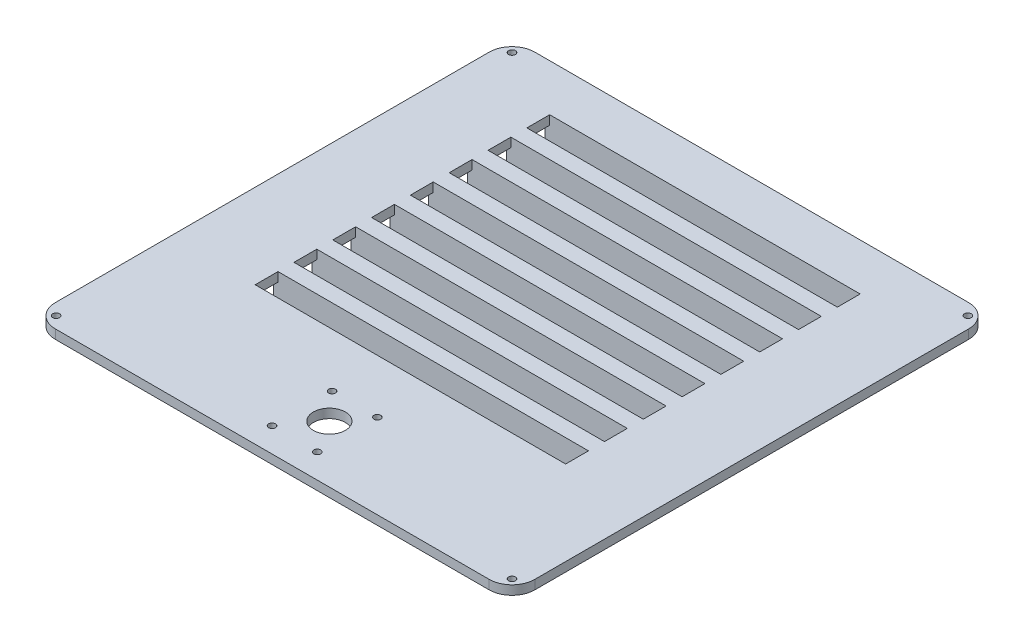
from build123d import *

# Parameters (mm, degrees)
SKETCH1_W               = 210
SKETCH1_H               = 210
MAINEXTRUDE_DEPTH       = 4
SKETCH1_6_R             = 1.5
SCREWHOLES_DEPTH        = 4
ROUNDEDCORNERS_R        = 10
SKETCH3_R               = 7
SKETCH3_R_2             = 1.5
SKETCH3_W               = 136
SKETCH3_H               = 10
TRENCH_DEPTH            = 10
SKETCH4_W               = 140
SKETCH4_H               = 14
SKETCH4_W_2             = 136
SKETCH4_H_2             = 10
TRENCH_WALLS_DEPTH      = 4
SKETCH5_W               = 140
SKETCH5_H               = 14
TRENCH_BOTTOM_DEPTH     = 2
SKETCH7_W               = 10
SKETCH7_H               = 6
WIRE_OPENING_DEPTH      = 36
WIRE_OPENING_DEPTH_BACK = 176
SKETCH9_R               = 2
SKETCH9_R_2             = 0.98
PCB_HOLES_DEPTH         = 4
PCB_ROUNDS_R            = 2


with BuildPart() as part:
    # Sketch1 → MainExtrude (new body)
    with BuildSketch(Plane(origin=(0, 0, 0), x_dir=(1, 0, 0), z_dir=(0, 1, 0))):
        Rectangle(SKETCH1_W, SKETCH1_H)
    extrude(amount=MAINEXTRUDE_DEPTH)

    # Sketch1_6 → ScrewHoles (cut)
    with BuildSketch(Plane(origin=(0, 0, 0), x_dir=(1, 0, 0), z_dir=(0, 1, 0))):
        with Locations((-99.833273811, 99.833273811)):
            Circle(SKETCH1_6_R)
        with Locations((-99.833273811, -99.833273811)):
            Circle(SKETCH1_6_R)
        with Locations((99.833273811, -99.833273811)):
            Circle(SKETCH1_6_R)
        with Locations((99.833273811, 99.833273811)):
            Circle(SKETCH1_6_R)
    extrude(amount=SCREWHOLES_DEPTH, mode=Mode.SUBTRACT)

    # RoundedCorners
    roundedcorners_edges = [part.edges().sort_by_distance(p)[0] for p in [
        (-105, 2, -105),
        (-105, 2, 105),
        (105, 2, 105),
        (105, 2, -105),
    ]]
    fillet(roundedcorners_edges, radius=ROUNDEDCORNERS_R)

    # Sketch3 → Trench (cut)
    with BuildSketch(Plane(origin=(0, 0, 0), x_dir=(1, 0, 0), z_dir=(0, 1, 0))):
        with Locations((0, -80)):
            Circle(SKETCH3_R)
        with Locations((-10.8, -68)):
            Circle(SKETCH3_R_2)
        with Locations((-10.8, -94.3)):
            Circle(SKETCH3_R_2)
        with Locations((9, -94.3)):
            Circle(SKETCH3_R_2)
        with Locations((9, -68)):
            Circle(SKETCH3_R_2)
        with Locations((0, 79.5)):
            Rectangle(SKETCH3_W, SKETCH3_H)
        with Locations((0, 62.5)):
            Rectangle(SKETCH3_W, SKETCH3_H)
        with Locations((0, 45.5)):
            Rectangle(SKETCH3_W, SKETCH3_H)
        with Locations((0, 28.5)):
            Rectangle(SKETCH3_W, SKETCH3_H)
        with Locations((0, 11.5)):
            Rectangle(SKETCH3_W, SKETCH3_H)
        with Locations((0, -5.5)):
            Rectangle(SKETCH3_W, SKETCH3_H)
        with Locations((0, -22.5)):
            Rectangle(SKETCH3_W, SKETCH3_H)
        with Locations((0, -39.5)):
            Rectangle(SKETCH3_W, SKETCH3_H)
    extrude(amount=TRENCH_DEPTH, mode=Mode.SUBTRACT)

    # Sketch4 → Trench Walls (add)
    with BuildSketch(Plane(origin=(0, 0, 0), x_dir=(1, 0, 0), z_dir=(0, 1, 0))):
        with Locations((0, 79.5)):
            Rectangle(SKETCH4_W, SKETCH4_H)
        with Locations((0, 79.5)):
            Rectangle(SKETCH4_W_2, SKETCH4_H_2, mode=Mode.SUBTRACT)
        with Locations((0, 62.5)):
            Rectangle(SKETCH4_W, SKETCH4_H)
        with Locations((0, 62.5)):
            Rectangle(SKETCH4_W_2, SKETCH4_H_2, mode=Mode.SUBTRACT)
        with Locations((0, 45.5)):
            Rectangle(SKETCH4_W, SKETCH4_H)
        with Locations((0, 45.5)):
            Rectangle(SKETCH4_W_2, SKETCH4_H_2, mode=Mode.SUBTRACT)
        with Locations((0, 28.5)):
            Rectangle(SKETCH4_W, SKETCH4_H)
        with Locations((0, 28.5)):
            Rectangle(SKETCH4_W_2, SKETCH4_H_2, mode=Mode.SUBTRACT)
        with Locations((0, 11.5)):
            Rectangle(SKETCH4_W, SKETCH4_H)
        with Locations((0, 11.5)):
            Rectangle(SKETCH4_W_2, SKETCH4_H_2, mode=Mode.SUBTRACT)
        with Locations((0, -5.5)):
            Rectangle(SKETCH4_W, SKETCH4_H)
        with Locations((0, -5.5)):
            Rectangle(SKETCH4_W_2, SKETCH4_H_2, mode=Mode.SUBTRACT)
        with Locations((0, -22.5)):
            Rectangle(SKETCH4_W, SKETCH4_H)
        with Locations((0, -22.5)):
            Rectangle(SKETCH4_W_2, SKETCH4_H_2, mode=Mode.SUBTRACT)
        with Locations((0, -39.5)):
            Rectangle(SKETCH4_W, SKETCH4_H)
        with Locations((0, -39.5)):
            Rectangle(SKETCH4_W_2, SKETCH4_H_2, mode=Mode.SUBTRACT)
    extrude(amount=-TRENCH_WALLS_DEPTH)

    # Sketch5 → Trench Bottom (add)
    with BuildSketch(Plane.XZ.offset(4)):
        with Locations((0, -79.5)):
            Rectangle(SKETCH5_W, SKETCH5_H)
        with Locations((0, -62.5)):
            Rectangle(SKETCH5_W, SKETCH5_H)
        with Locations((0, -45.5)):
            Rectangle(SKETCH5_W, SKETCH5_H)
        with Locations((0, -28.5)):
            Rectangle(SKETCH5_W, SKETCH5_H)
        with Locations((0, -11.5)):
            Rectangle(SKETCH5_W, SKETCH5_H)
        with Locations((0, 5.5)):
            Rectangle(SKETCH5_W, SKETCH5_H)
        with Locations((0, 22.5)):
            Rectangle(SKETCH5_W, SKETCH5_H)
        with Locations((0, 39.5)):
            Rectangle(SKETCH5_W, SKETCH5_H)
    extrude(amount=TRENCH_BOTTOM_DEPTH)

    # Sketch7 → Wire Opening (cut, two sides)
    with BuildSketch(Plane(origin=(70, 0, 0), x_dir=(0, 0, -1), z_dir=(1, 0, 0))) as wire_opening_sk:
        with Locations((-39.5, -3)):
            Rectangle(SKETCH7_W, SKETCH7_H)
        with Locations((-22.5, -3)):
            Rectangle(SKETCH7_W, SKETCH7_H)
        with Locations((-5.5, -3)):
            Rectangle(SKETCH7_W, SKETCH7_H)
        with Locations((11.5, -3)):
            Rectangle(SKETCH7_W, SKETCH7_H)
        with Locations((28.5, -3)):
            Rectangle(SKETCH7_W, SKETCH7_H)
        with Locations((45.5, -3)):
            Rectangle(SKETCH7_W, SKETCH7_H)
        with Locations((62.5, -3)):
            Rectangle(SKETCH7_W, SKETCH7_H)
        with Locations((79.5, -3)):
            Rectangle(SKETCH7_W, SKETCH7_H)
    extrude(amount=WIRE_OPENING_DEPTH, mode=Mode.SUBTRACT)
    extrude(wire_opening_sk.sketch, amount=-WIRE_OPENING_DEPTH_BACK, mode=Mode.SUBTRACT)

    # Sketch9 → PCB Holes (add)
    with BuildSketch(Plane.XZ):
        with Locations((-94, 92)):
            Circle(SKETCH9_R)
        with Locations((-94, 92)):
            Circle(SKETCH9_R_2, mode=Mode.SUBTRACT)
        with Locations((-19.73, 92)):
            Circle(SKETCH9_R)
        with Locations((-19.73, 92)):
            Circle(SKETCH9_R_2, mode=Mode.SUBTRACT)
        with Locations((-94, 56.16)):
            Circle(SKETCH9_R)
        with Locations((-94, 56.16)):
            Circle(SKETCH9_R_2, mode=Mode.SUBTRACT)
        with Locations((-19.73, 56.16)):
            Circle(SKETCH9_R)
        with Locations((-19.73, 56.16)):
            Circle(SKETCH9_R_2, mode=Mode.SUBTRACT)
    extrude(amount=PCB_HOLES_DEPTH)

    # PCB Rounds
    pcb_rounds_edges = [part.edges().sort_by_distance(p)[0] for p in [
        (-96, 0, 92),
        (-21.73, 0, 56.16),
        (-96, 0, 56.16),
        (-21.73, 0, 92),
    ]]
    fillet(pcb_rounds_edges, radius=PCB_ROUNDS_R)


solid = part.part
